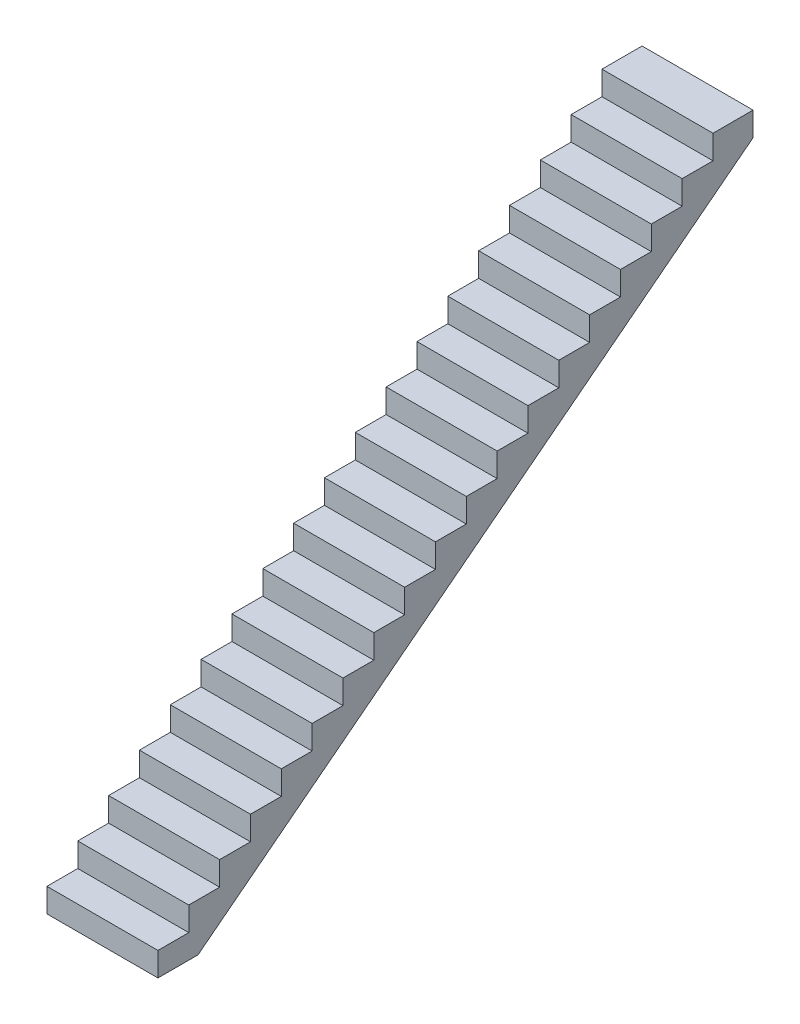
from build123d import *

# Parameters (mm, degrees)
SKETCH1_W                  = 254
SKETCH1_H                  = 196.85
MODELSTEP_DEPTH            = 457.2
SKETCH4_W                  = 914.4
SKETCH4_H                  = 196.85
EXTRUDEMAXSTAIRWIDTH_DEPTH = 76.2
PATTERN_STAIRS_COUNT       = 19
PATTERN_STAIRS_PITCH       = 321.350155594
COMBINESTAIRS_START        = -155.593203
SKETCH5_W                  = 914.4
SKETCH5_H                  = 5784.302800684
COMBINESTAIRS_DEPTH        = 155.593203


with BuildPart() as part:
    # Sketch1 → ModelStep (new body, symmetric)
    with BuildSketch(Plane(origin=(0, 0, 0), x_dir=(0, 0, -1), z_dir=(1, 0, 0))):
        with Locations((127, 98.425)):
            Rectangle(SKETCH1_W, SKETCH1_H)
    extrude(amount=MODELSTEP_DEPTH, both=True)

    # Sketch4 → ExtrudeMaxStairWidth (add)
    with BuildSketch(Plane(origin=(0, 0, -254), x_dir=(-1, 0, 0), z_dir=(0, 0, -1))):
        with Locations((0, 98.425)):
            Rectangle(SKETCH4_W, SKETCH4_H)
    extrude(amount=EXTRUDEMAXSTAIRWIDTH_DEPTH)


with BuildPart() as pattern_stairs_1:
    # Pattern stairs: pattern copy
    add(part.part.moved(Location(Vector(0, 0.612571665, -0.790415052) * (1 * PATTERN_STAIRS_PITCH))))


with BuildPart() as pattern_stairs_2:
    # Pattern stairs: pattern copy
    add(part.part.moved(Location(Vector(0, 0.612571665, -0.790415052) * (2 * PATTERN_STAIRS_PITCH))))


with BuildPart() as pattern_stairs_3:
    # Pattern stairs: pattern copy
    add(part.part.moved(Location(Vector(0, 0.612571665, -0.790415052) * (3 * PATTERN_STAIRS_PITCH))))


with BuildPart() as pattern_stairs_4:
    # Pattern stairs: pattern copy
    add(part.part.moved(Location(Vector(0, 0.612571665, -0.790415052) * (4 * PATTERN_STAIRS_PITCH))))


with BuildPart() as pattern_stairs_5:
    # Pattern stairs: pattern copy
    add(part.part.moved(Location(Vector(0, 0.612571665, -0.790415052) * (5 * PATTERN_STAIRS_PITCH))))


with BuildPart() as pattern_stairs_6:
    # Pattern stairs: pattern copy
    add(part.part.moved(Location(Vector(0, 0.612571665, -0.790415052) * (6 * PATTERN_STAIRS_PITCH))))


with BuildPart() as pattern_stairs_7:
    # Pattern stairs: pattern copy
    add(part.part.moved(Location(Vector(0, 0.612571665, -0.790415052) * (7 * PATTERN_STAIRS_PITCH))))


with BuildPart() as pattern_stairs_8:
    # Pattern stairs: pattern copy
    add(part.part.moved(Location(Vector(0, 0.612571665, -0.790415052) * (8 * PATTERN_STAIRS_PITCH))))


with BuildPart() as pattern_stairs_9:
    # Pattern stairs: pattern copy
    add(part.part.moved(Location(Vector(0, 0.612571665, -0.790415052) * (9 * PATTERN_STAIRS_PITCH))))


with BuildPart() as pattern_stairs_10:
    # Pattern stairs: pattern copy
    add(part.part.moved(Location(Vector(0, 0.612571665, -0.790415052) * (10 * PATTERN_STAIRS_PITCH))))


with BuildPart() as pattern_stairs_11:
    # Pattern stairs: pattern copy
    add(part.part.moved(Location(Vector(0, 0.612571665, -0.790415052) * (11 * PATTERN_STAIRS_PITCH))))


with BuildPart() as pattern_stairs_12:
    # Pattern stairs: pattern copy
    add(part.part.moved(Location(Vector(0, 0.612571665, -0.790415052) * (12 * PATTERN_STAIRS_PITCH))))


with BuildPart() as pattern_stairs_13:
    # Pattern stairs: pattern copy
    add(part.part.moved(Location(Vector(0, 0.612571665, -0.790415052) * (13 * PATTERN_STAIRS_PITCH))))


with BuildPart() as pattern_stairs_14:
    # Pattern stairs: pattern copy
    add(part.part.moved(Location(Vector(0, 0.612571665, -0.790415052) * (14 * PATTERN_STAIRS_PITCH))))


with BuildPart() as pattern_stairs_15:
    # Pattern stairs: pattern copy
    add(part.part.moved(Location(Vector(0, 0.612571665, -0.790415052) * (15 * PATTERN_STAIRS_PITCH))))


with BuildPart() as pattern_stairs_16:
    # Pattern stairs: pattern copy
    add(part.part.moved(Location(Vector(0, 0.612571665, -0.790415052) * (16 * PATTERN_STAIRS_PITCH))))


with BuildPart() as pattern_stairs_17:
    # Pattern stairs: pattern copy
    add(part.part.moved(Location(Vector(0, 0.612571665, -0.790415052) * (17 * PATTERN_STAIRS_PITCH))))


with BuildPart() as pattern_stairs_18:
    # Pattern stairs: pattern copy
    add(part.part.moved(Location(Vector(0, 0.612571665, -0.790415052) * (18 * PATTERN_STAIRS_PITCH))))


with BuildPart() as part_1:
    add(part.part)

    add(pattern_stairs_1.part)  # CombineStairs merges Pattern stairs_1

    add(pattern_stairs_2.part)  # CombineStairs merges Pattern stairs_2

    add(pattern_stairs_3.part)  # CombineStairs merges Pattern stairs_3

    add(pattern_stairs_4.part)  # CombineStairs merges Pattern stairs_4

    add(pattern_stairs_5.part)  # CombineStairs merges Pattern stairs_5

    add(pattern_stairs_6.part)  # CombineStairs merges Pattern stairs_6

    add(pattern_stairs_7.part)  # CombineStairs merges Pattern stairs_7

    add(pattern_stairs_8.part)  # CombineStairs merges Pattern stairs_8

    add(pattern_stairs_9.part)  # CombineStairs merges Pattern stairs_9

    add(pattern_stairs_10.part)  # CombineStairs merges Pattern stairs_10

    add(pattern_stairs_11.part)  # CombineStairs merges Pattern stairs_11

    add(pattern_stairs_12.part)  # CombineStairs merges Pattern stairs_12

    add(pattern_stairs_13.part)  # CombineStairs merges Pattern stairs_13

    add(pattern_stairs_14.part)  # CombineStairs merges Pattern stairs_14

    add(pattern_stairs_15.part)  # CombineStairs merges Pattern stairs_15

    add(pattern_stairs_16.part)  # CombineStairs merges Pattern stairs_16

    add(pattern_stairs_17.part)  # CombineStairs merges Pattern stairs_17

    add(pattern_stairs_18.part)  # CombineStairs merges Pattern stairs_18
    # Sketch5 → CombineStairs (add)
    with BuildSketch(Plane(origin=(0, -159.878172589, -123.905583756), x_dir=(-1, 0, 0), z_dir=(0, -0.790415052, -0.612571665)).offset(COMBINESTAIRS_START)):
        with Locations((0, 3153.14645057)):
            Rectangle(SKETCH5_W, SKETCH5_H)
    extrude(amount=COMBINESTAIRS_DEPTH)


solid = part_1.part
